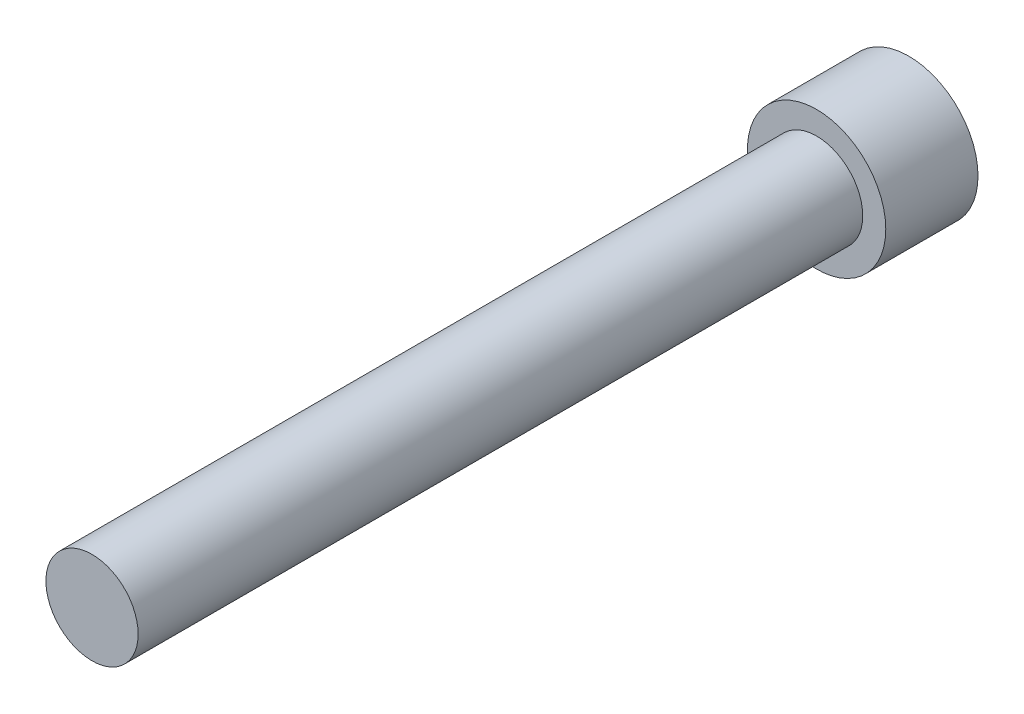
from build123d import *

# Parameters (mm, degrees)
SKETCH_1_R      = 10.5
EXTRUDE_1_DEPTH = 14
SKETCH_2_R      = 7
EXTRUDE_2_DEPTH = 110


with BuildPart() as part:
    # 草图1 → 凸台-拉伸1 (new body)
    with BuildSketch(Plane.XY):
        with Locations((-16.410483799, 16.544995961)):
            Circle(SKETCH_1_R)
    extrude(amount=EXTRUDE_1_DEPTH)

    # 草图2 → 凸台-拉伸2 (add)
    with BuildSketch(Plane.XY.offset(14)):
        with Locations((-16.410483799, 16.544995961)):
            Circle(SKETCH_2_R)
    extrude(amount=EXTRUDE_2_DEPTH)


solid = part.part
